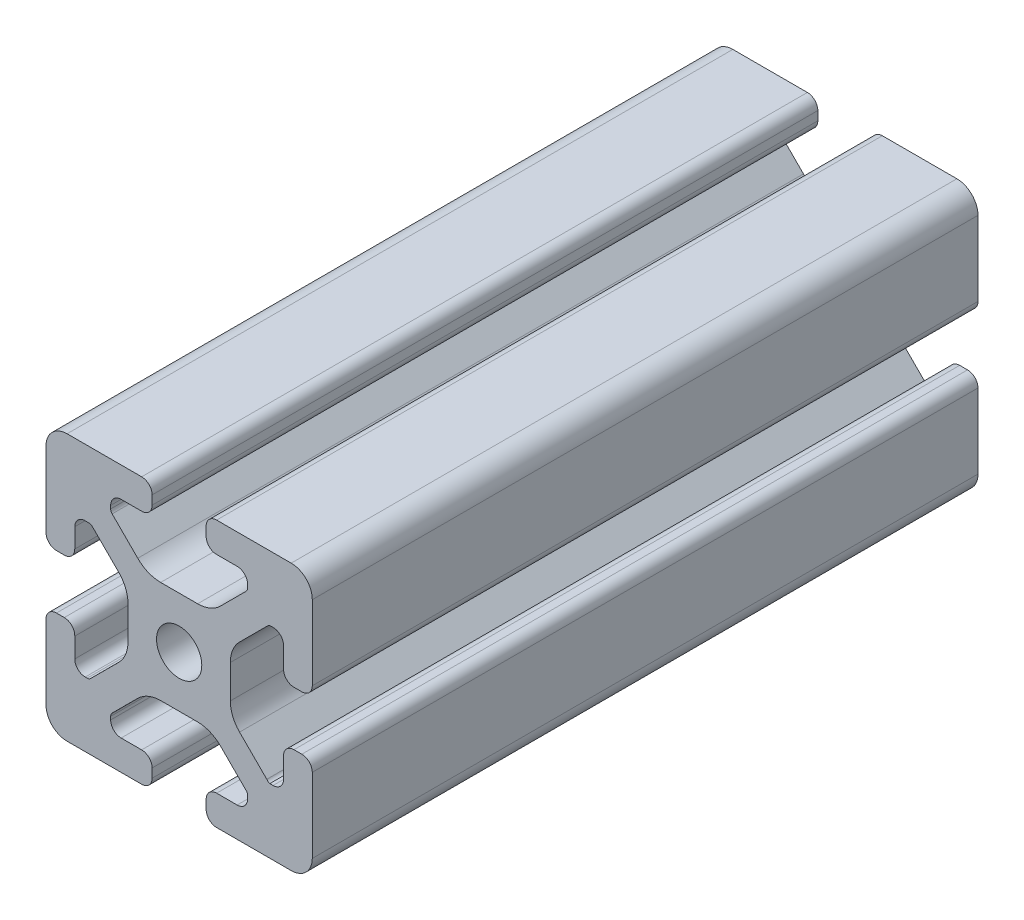
from build123d import *

# Parameters (mm, degrees)
SKETCH1_R           = 3.4
BOSS_EXTRUDE1_DEPTH = 100


with BuildPart() as part:
    # Sketch1 → Boss-Extrude1 (new body)
    with BuildSketch(Plane.XY):
        with BuildLine():
            Line((-8.715, -15.524615034), (-5.63, -15.524615034))
            ThreePointArc((-5.63, -15.524615034), (-4.519842354, -15.984457388), (-4.06, -17.094615034))
            Line((-4.06, -17.094615034), (-4.06, -18.43))
            ThreePointArc((-4.06, -18.43), (-4.519842354, -19.540157646), (-5.63, -20))
            Line((-5.63, -20), (-16.674615034, -20))
            ThreePointArc((-16.674615034, -20), (-18.951578385, -19.194274381), (-20, -17.018368134))
            Line((-20, -17.018368134), (-20, -5.757918808))
            ThreePointArc((-20, -5.757918808), (-19.564709668, -4.603883664), (-18.43, -4.120449326))
            Line((-18.43, -4.120449326), (-17.248545805, -4.120449326))
            ThreePointArc((-17.248545805, -4.120449326), (-16.114784845, -4.604407881), (-15.67999625, -5.757919334))
            Line((-15.67999625, -5.757919334), (-15.67999625, -8.715399492))
            ThreePointArc((-15.67999625, -8.715399492), (-15.220153896, -9.825557139), (-14.10999625, -10.285399492))
            Line((-14.10999625, -10.285399492), (-13.816903094, -10.285399492))
            ThreePointArc((-13.816903094, -10.285399492), (-13.526063686, -10.227547937), (-13.279501941, -10.062800646))
            Line((-13.279501941, -10.062800646), (-9.076242789, -5.859541495))
            ThreePointArc((-9.076242789, -5.859541495), (-8.046572221, -4.318530588), (-7.685, -2.500784284))
            Line((-7.685, -2.500784284), (-7.685, 2.500784284))
            ThreePointArc((-7.685, 2.500784284), (-8.046572221, 4.318530588), (-9.076242789, 5.859541495))
            Line((-9.076242789, 5.859541495), (-13.040489136, 9.823787841))
            ThreePointArc((-13.040489136, 9.823787841), (-13.354224618, 10.012729352), (-13.71989919, 10.033001362))
            Line((-13.71989919, 10.033001362), (-14.05520779, 10.044710596))
            ThreePointArc((-14.05520779, 10.044710596), (-15.200613642, 9.605030484), (-15.68, 8.475666998))
            Line((-15.68, 8.475666998), (-15.68, 5.572979049))
            ThreePointArc((-15.68, 5.572979049), (-16.139842354, 4.462821403), (-17.25, 4.002979049))
            Line((-17.25, 4.002979049), (-18.43, 4.002979049))
            ThreePointArc((-18.43, 4.002979049), (-19.540157646, 4.462821403), (-20, 5.572979049))
            Line((-20, 5.572979049), (-20, 13.004526564))
            Line((-20, 13.004526564), (-20, 16.83))
            ThreePointArc((-20, 16.83), (-19.071528496, 19.071528496), (-16.83, 20))
            Line((-16.83, 20), (-5.63, 20))
            ThreePointArc((-5.63, 20), (-4.519842354, 19.540157646), (-4.06, 18.43))
            Line((-4.06, 18.43), (-4.06, 17.094615034))
            ThreePointArc((-4.06, 17.094615034), (-4.519842354, 15.984457388), (-5.63, 15.524615034))
            Line((-5.63, 15.524615034), (-8.715, 15.524615034))
            ThreePointArc((-8.715, 15.524615034), (-9.825157646, 15.06477268), (-10.285, 13.954615034))
            Line((-10.285, 13.954615034), (-10.285, 13.492503602))
            ThreePointArc((-10.285, 13.492503602), (-10.227148445, 13.201664194), (-10.062401154, 12.955102448))
            Line((-10.062401154, 12.955102448), (-6.217092793, 9.109794088))
            ThreePointArc((-6.217092793, 9.109794088), (-4.63891877, 8.055291919), (-2.777335583, 7.685))
            Line((-2.777335583, 7.685), (2.777335583, 7.685))
            ThreePointArc((2.777335583, 7.685), (4.63891877, 8.055291919), (6.217092793, 9.109794088))
            Line((6.217092793, 9.109794088), (10.062401154, 12.955102448))
            ThreePointArc((10.062401154, 12.955102448), (10.227148445, 13.201664194), (10.285, 13.492503602))
            Line((10.285, 13.492503602), (10.285, 13.954615034))
            ThreePointArc((10.285, 13.954615034), (9.825157646, 15.06477268), (8.715, 15.524615034))
            Line((8.715, 15.524615034), (5.63, 15.524615034))
            ThreePointArc((5.63, 15.524615034), (4.519842354, 15.984457388), (4.06, 17.094615034))
            Line((4.06, 17.094615034), (4.06, 18.43))
            ThreePointArc((4.06, 18.43), (4.519842354, 19.540157646), (5.63, 20))
            Line((5.63, 20), (12.979635074, 20))
            Line((12.979635074, 20), (16.83, 20))
            ThreePointArc((16.83, 20), (19.071528496, 19.071528496), (20, 16.83))
            Line((20, 16.83), (20, 13.001098436))
            Line((20, 13.001098436), (20, 5.630000526))
            ThreePointArc((20, 5.630000526), (19.540157646, 4.519842879), (18.43, 4.060000526))
            Line((18.43, 4.060000526), (17.24999625, 4.060000526))
            ThreePointArc((17.24999625, 4.060000526), (16.139838603, 4.519842879), (15.67999625, 5.630000526))
            Line((15.67999625, 5.630000526), (15.67999625, 8.715399492))
            ThreePointArc((15.67999625, 8.715399492), (15.220153896, 9.825557139), (14.10999625, 10.285399492))
            Line((14.10999625, 10.285399492), (13.816903094, 10.285399492))
            ThreePointArc((13.816903094, 10.285399492), (13.526063686, 10.227547937), (13.279501941, 10.062800646))
            Line((13.279501941, 10.062800646), (9.076242789, 5.859541495))
            ThreePointArc((9.076242789, 5.859541495), (8.046572221, 4.318530588), (7.685, 2.500784284))
            Line((7.685, 2.500784284), (7.685, -2.500784284))
            ThreePointArc((7.685, -2.500784284), (8.046572221, -4.318530588), (9.076242789, -5.859541495))
            Line((9.076242789, -5.859541495), (13.163657296, -9.946956002))
            ThreePointArc((13.163657296, -9.946956002), (13.35903797, -10.160433474), (13.6200547, -10.285399492))
            Line((13.6200547, -10.285399492), (14.10999625, -10.285399492))
            ThreePointArc((14.10999625, -10.285399492), (15.220153896, -9.825557139), (15.67999625, -8.715399492))
            Line((15.67999625, -8.715399492), (15.67999625, -5.630000526))
            ThreePointArc((15.67999625, -5.630000526), (16.139838603, -4.519842879), (17.24999625, -4.060000526))
            Line((17.24999625, -4.060000526), (18.43, -4.060000526))
            ThreePointArc((18.43, -4.060000526), (19.540157646, -4.519842879), (20, -5.630000526))
            Line((20, -5.630000526), (20, -16.83))
            ThreePointArc((20, -16.83), (19.071528496, -19.071528496), (16.83, -20))
            Line((16.83, -20), (13, -20))
            Line((13, -20), (5.63, -20))
            ThreePointArc((5.63, -20), (4.519842354, -19.540157646), (4.06, -18.43))
            Line((4.06, -18.43), (4.06, -17.094615034))
            ThreePointArc((4.06, -17.094615034), (4.519842354, -15.984457388), (5.63, -15.524615034))
            Line((5.63, -15.524615034), (8.715, -15.524615034))
            ThreePointArc((8.715, -15.524615034), (9.825157646, -15.06477268), (10.285, -13.954615034))
            Line((10.285, -13.954615034), (10.285, -13.492503602))
            ThreePointArc((10.285, -13.492503602), (10.227148445, -13.201664194), (10.062401154, -12.955102448))
            Line((10.062401154, -12.955102448), (6.217092793, -9.109794088))
            ThreePointArc((6.217092793, -9.109794088), (4.63891877, -8.055291919), (2.777335583, -7.685))
            Line((2.777335583, -7.685), (-2.777335583, -7.685))
            ThreePointArc((-2.777335583, -7.685), (-4.63891877, -8.055291919), (-6.217092793, -9.109794088))
            Line((-6.217092793, -9.109794088), (-10.062401154, -12.955102448))
            ThreePointArc((-10.062401154, -12.955102448), (-10.227148445, -13.201664194), (-10.285, -13.492503602))
            Line((-10.285, -13.492503602), (-10.285, -13.954615034))
            ThreePointArc((-10.285, -13.954615034), (-9.825157646, -15.06477268), (-8.715, -15.524615034))
        make_face()
        Circle(SKETCH1_R, mode=Mode.SUBTRACT)
    extrude(amount=BOSS_EXTRUDE1_DEPTH)


solid = part.part
